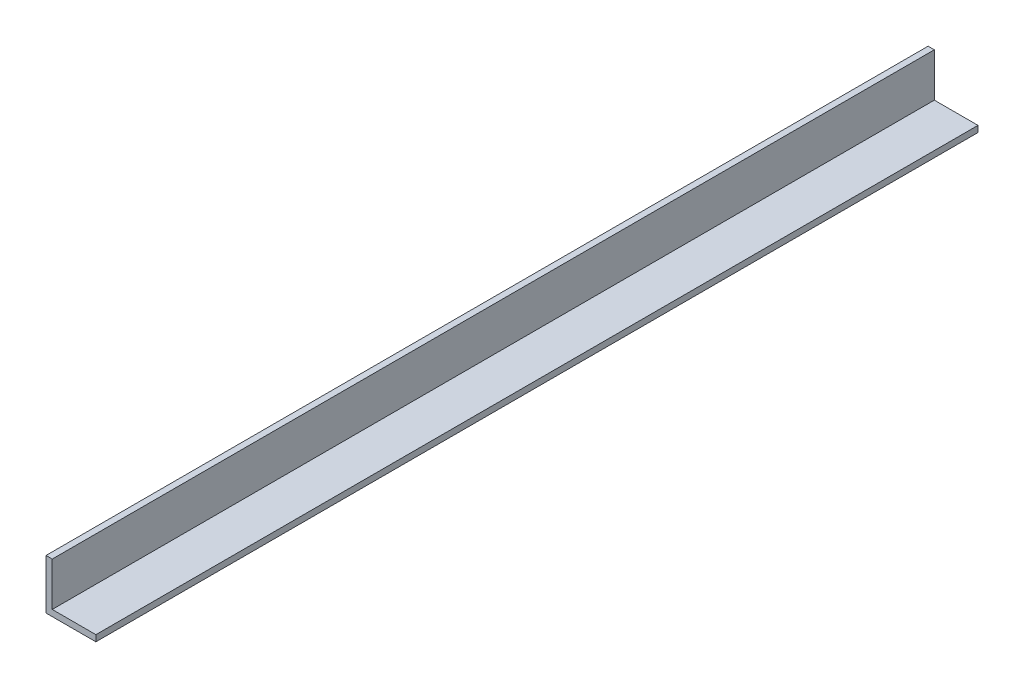
from build123d import *

# Parameters (mm, degrees)
BOSS_EXTRUDE1_DEPTH = 224.6


with BuildPart() as part:
    # Sketch1 → Boss-Extrude1 (new body, symmetric)
    with BuildSketch(Plane.XY):
        Polygon((0, 25.4), (0, 0), (25.4, 0), (25.4, 3.175), (3.175, 3.175), (3.175, 25.4), align=None)
    extrude(amount=BOSS_EXTRUDE1_DEPTH, both=True)


solid = part.part
